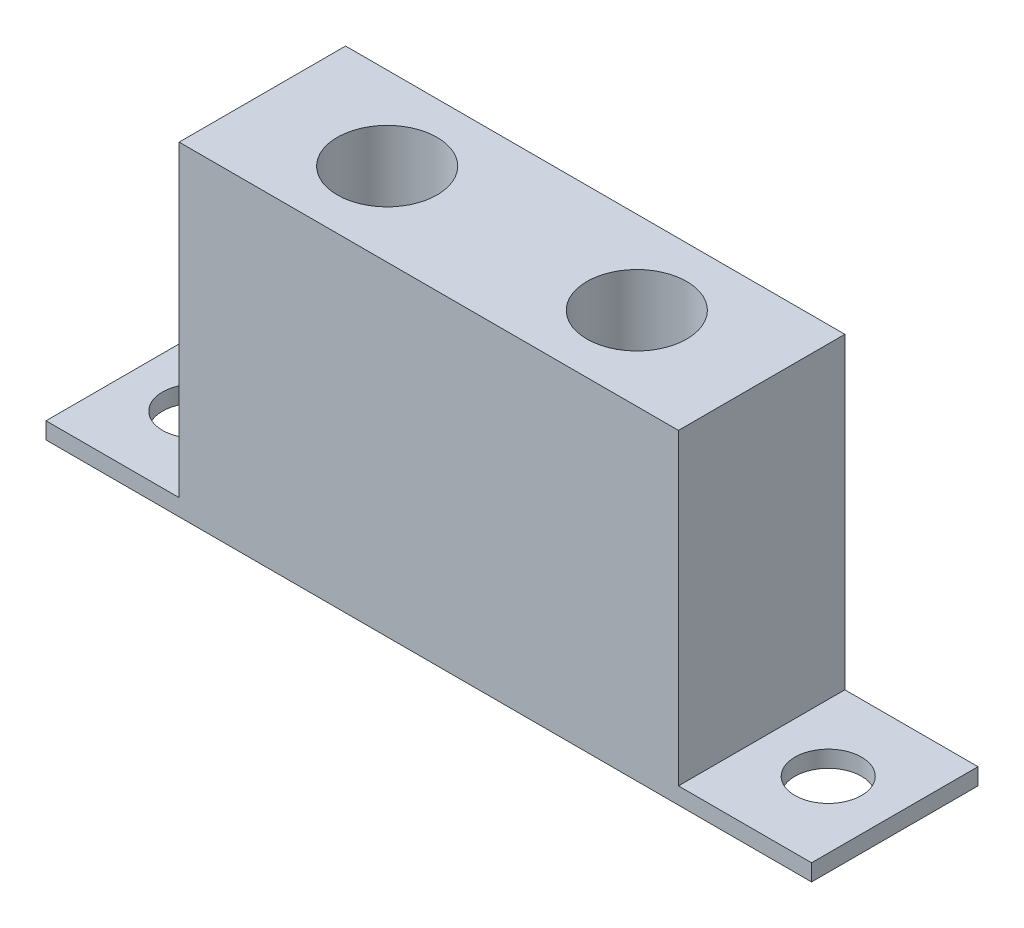
from build123d import *

# Parameters (mm, degrees)
SKETCH1_W           = 15
SKETCH1_H           = 5
BOSS_EXTRUDE1_DEPTH = 9.75
SKETCH2_R           = 1.5
CUT_EXTRUDE1_DEPTH  = 4
SKETCH3_W           = 5
SKETCH3_H           = 0.5
BOSS_EXTRUDE2_DEPTH = 4
SKETCH4_W           = 5
SKETCH4_H           = 0.5
BOSS_EXTRUDE3_DEPTH = 4
SKETCH5_R           = 1
CUT_EXTRUDE2_DEPTH  = 4


with BuildPart() as part:
    # Sketch1 → Boss-Extrude1 (new body)
    with BuildSketch(Plane(origin=(0, 0, 0), x_dir=(1, 0, 0), z_dir=(0, 1, 0))):
        with Locations((-0.341726619, 0)):
            Rectangle(SKETCH1_W, SKETCH1_H)
    extrude(amount=BOSS_EXTRUDE1_DEPTH)

    # Sketch2 → Cut-Extrude1 (cut)
    with BuildSketch(Plane(origin=(0, 9.75, 0), x_dir=(1, 0, 0), z_dir=(0, 1, 0))):
        with Locations((-4.091726619, 0)):
            Circle(SKETCH2_R)
        with Locations((3.408273381, 0)):
            Circle(SKETCH2_R)
    extrude(amount=-CUT_EXTRUDE1_DEPTH, mode=Mode.SUBTRACT)

    # Sketch3 → Boss-Extrude2 (add)
    with BuildSketch(Plane(origin=(7.158273381, 0, 0), x_dir=(0, 0, -1), z_dir=(1, 0, 0))):
        with Locations((0, 0.25)):
            Rectangle(SKETCH3_W, SKETCH3_H)
    extrude(amount=BOSS_EXTRUDE2_DEPTH)

    # Sketch4 → Boss-Extrude3 (add)
    with BuildSketch(Plane.ZY.offset(7.841726619)):
        with Locations((0, 0.25)):
            Rectangle(SKETCH4_W, SKETCH4_H)
    extrude(amount=BOSS_EXTRUDE3_DEPTH)

    # Sketch5 → Cut-Extrude2 (cut)
    with BuildSketch(Plane(origin=(0, 0.5, 0), x_dir=(1, 0, 0), z_dir=(0, 1, 0))):
        with Locations((-9.841726619, 0)):
            Circle(SKETCH5_R)
        with Locations((9.158273381, 0)):
            Circle(SKETCH5_R)
    extrude(amount=-CUT_EXTRUDE2_DEPTH, mode=Mode.SUBTRACT)


solid = part.part
